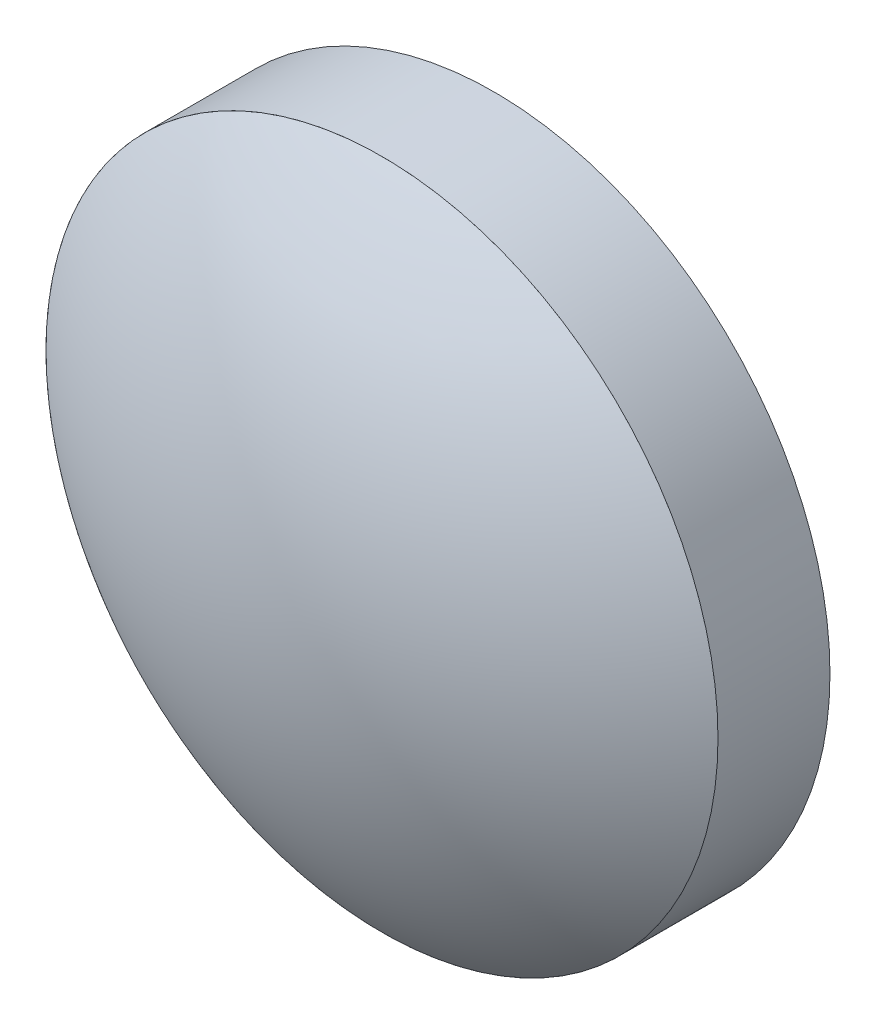
from build123d import *

# Parameters (mm, degrees)
SKETCH1_R           = 6
BOSS_EXTRUDE1_DEPTH = 2
SKETCH4_R           = 0.75
CUT_EXTRUDE1_DEPTH  = 0.2


with BuildPart() as part:
    # Sketch1 → Boss-Extrude1 (new body)
    with BuildSketch(Plane.XY):
        Circle(SKETCH1_R)
    extrude(amount=BOSS_EXTRUDE1_DEPTH)

    # Sketch4 → Cut-Extrude1 (cut)
    with BuildSketch(Plane.XY.offset(2)):
        Circle(SKETCH4_R)
    extrude(amount=-CUT_EXTRUDE1_DEPTH, mode=Mode.SUBTRACT)


with BuildPart() as body_2:
    # Sketch2 → Revolve1 (revolve)
    with BuildSketch(Plane(origin=(0, 0, 0), x_dir=(1, 0, 0), z_dir=(0, 1, 0))):
        with BuildLine():
            Line((-6, -2), (-5.485435261, -2))
            ThreePointArc((-5.485435261, -2), (-2.871410803, -3.265257687), (0, -3.7))
            Line((0, -3.7), (0, -4))
            ThreePointArc((0, -4), (-3.16227766, -3.486832981), (-6, -2))
        make_face()
    revolve(axis=Axis((0, 0, 0), (0, 0, -1)))


with BuildPart() as body_3:
    # Sketch3 → Revolve2 (revolve)
    with BuildSketch(Plane(origin=(0, 0, 0), x_dir=(1, 0, 0), z_dir=(0, 1, 0))):
        with BuildLine():
            Line((-1.6, -2), (-1.3, -2))
            ThreePointArc((-1.3, -2), (-0.919238816, -2.919238816), (0, -3.3))
            Line((0, -3.3), (0, -3.6))
            ThreePointArc((0, -3.6), (-1.13137085, -3.13137085), (-1.6, -2))
        make_face()
    revolve(axis=Axis((0, 0, 0), (0, 0, -1)))


solid = Compound([part.part, body_2.part, body_3.part])
